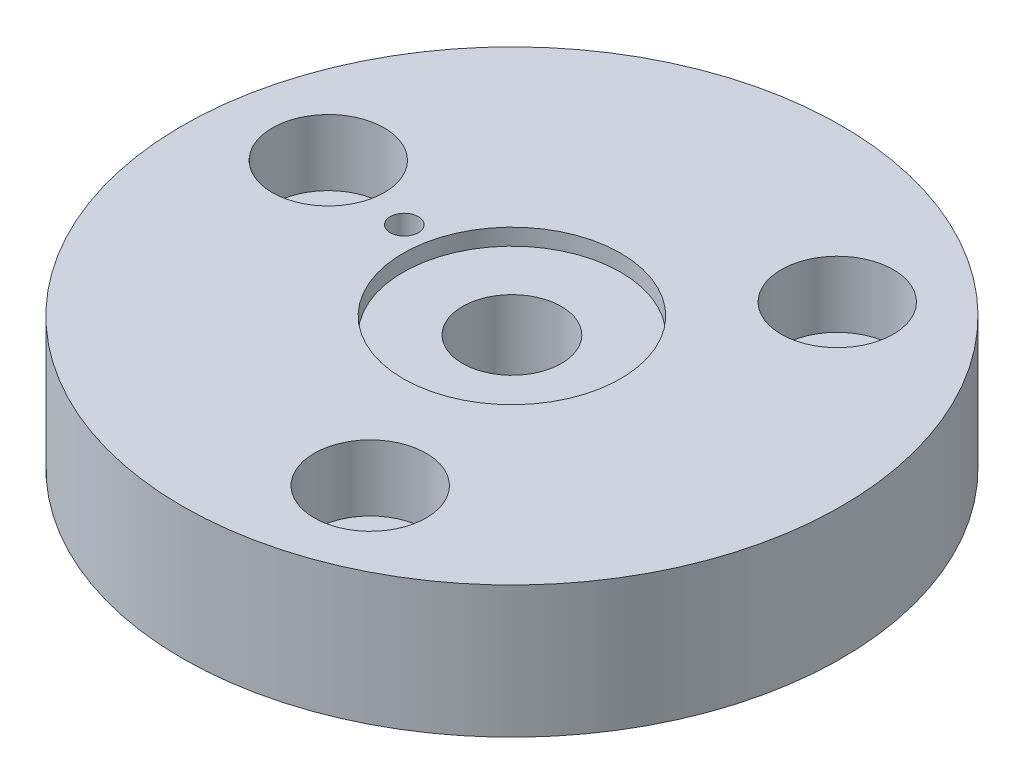
from build123d import *

# Parameters (mm, degrees)
ESQUISSE1_R                  = 100
ESQUISSE1_R_2                = 4.25
ESQUISSE1_R_3                = 8
BOSS_EXTRU_1_DEPTH           = 40
ESQUISSE3_R                  = 5
ENL_V_MAT_EXTRU_2_DEPTH      = 41
ESQUISSE5_R                  = 15
ENL_V_MAT_EXTRU_3_DEPTH      = 30
ESQUISSE6_R                  = 33
ENL_V_MAT_EXTRU_4_DEPTH      = 5
ESQUISSE8_R                  = 17
ENL_V_MAT_EXTRU_5_DEPTH      = 20
R_P_TITION_CIRCULAIRE1_COUNT = 3


with BuildPart() as part:
    # Esquisse1 → Boss.-Extru.1 (new body)
    with BuildSketch(Plane(origin=(0, 0, 0), x_dir=(1, 0, 0), z_dir=(0, 1, 0))):
        with Locations(Location((0, 0, 0), (0, 0, 270))):  # turned: the seam where the file's is
            Circle(ESQUISSE1_R)
        with Locations(Location((-40.311740852, 7.648092634, 0), (0, 0, 270))):  # turned: the seam where the file's is
            Circle(ESQUISSE1_R_2, mode=Mode.SUBTRACT)
        with Locations(Location((-68.947262615, 13.080929779, 0), (0, 0, 270))):  # turned: the seam where the file's is
            Circle(ESQUISSE1_R_3, mode=Mode.SUBTRACT)
        with Locations(Location((45.802048801, 53.169616056, 0), (0, 0, 270))):  # turned: the seam where the file's is
            Circle(ESQUISSE1_R_3, mode=Mode.SUBTRACT)
        with Locations(Location((23.145213813, -66.250545836, 0), (0, 0, 270))):  # turned: the seam where the file's is
            Circle(ESQUISSE1_R_3, mode=Mode.SUBTRACT)
    extrude(amount=-BOSS_EXTRU_1_DEPTH)

    # Esquisse3 → Enlèv. mat.-Extru.2 (cut, through all)
    with BuildSketch(Plane(origin=(0, 0, 0), x_dir=(1, 0, 0), z_dir=(0, 1, 0))):
        with Locations(Location((0, 0, 0), (0, 0, 270))):  # turned: the seam where the file's is
            Circle(ESQUISSE3_R)
    extrude(amount=-ENL_V_MAT_EXTRU_2_DEPTH, mode=Mode.SUBTRACT)

    # Esquisse5 → Enlèv. mat.-Extru.3 (cut)
    with BuildSketch(Plane(origin=(0, 0, 0), x_dir=(1, 0, 0), z_dir=(0, 1, 0))):
        with Locations(Location((0, 0, 0), (0, 0, 270))):  # turned: the seam where the file's is
            Circle(ESQUISSE5_R)
    extrude(amount=-ENL_V_MAT_EXTRU_3_DEPTH, mode=Mode.SUBTRACT)

    # Esquisse6 → Enlèv. mat.-Extru.4 (cut)
    with BuildSketch(Plane(origin=(0, 0, 0), x_dir=(1, 0, 0), z_dir=(0, 1, 0))):
        with Locations(Location((0, 0, 0), (0, 0, 270))):  # turned: the seam where the file's is
            Circle(ESQUISSE6_R)
    extrude(amount=-ENL_V_MAT_EXTRU_4_DEPTH, mode=Mode.SUBTRACT)

    # Esquisse8 → Enlèv. mat.-Extru.5 (cut)
    with BuildSketch(Plane(origin=(0, 0, 0), x_dir=(1, 0, 0), z_dir=(0, 1, 0))):
        with Locations(Location((-68.773193764, 13.047904793, 0), (0, 0, 270))):  # turned: the seam where the file's is
            Circle(ESQUISSE8_R)
    enl_v_mat_extru_5 = extrude(amount=-ENL_V_MAT_EXTRU_5_DEPTH, mode=Mode.SUBTRACT)

    # Répétition circulaire1: Enlèv. mat.-Extru.5 ×3 about axis
    r_p_tition_circulaire1_axis = Axis((0, 0, 0), (0, 1, 0))
    for i in range(1, R_P_TITION_CIRCULAIRE1_COUNT):
        add(enl_v_mat_extru_5.rotate(r_p_tition_circulaire1_axis, i * 360 / R_P_TITION_CIRCULAIRE1_COUNT), mode=Mode.SUBTRACT)


solid = part.part
